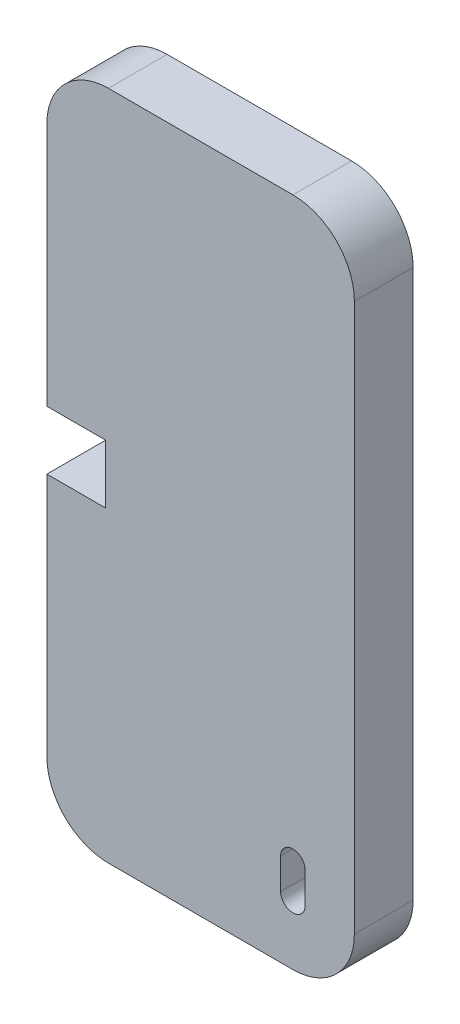
from build123d import *

# Parameters (mm, degrees)
BOSS_EXTRUDE1_DEPTH = 4.7752
SKETCH4_W           = 4.7752
SKETCH4_H           = 4.7752
CUT_EXTRUDE1_DEPTH  = 5.7752
CUT_EXTRUDE2_DEPTH  = 10


with BuildPart() as part:
    # Sketch1 → Boss-Extrude1 (new body)
    with BuildSketch(Plane.XY):
        with BuildLine():
            Line((-4.5504, 44.7752), (-4.5504, 0.2248))
            ThreePointArc((-4.5504, 0.2248), (-3.085933906, -3.310733906), (0.4496, -4.7752))
            Line((0.4496, -4.7752), (15.4496, -4.7752))
            ThreePointArc((15.4496, -4.7752), (18.985133906, -3.310733906), (20.4496, 0.2248))
            Line((20.4496, 0.2248), (20.4496, 44.7752))
            ThreePointArc((20.4496, 44.7752), (18.985133906, 48.310733906), (15.4496, 49.7752))
            Line((15.4496, 49.7752), (0.4496, 49.7752))
            ThreePointArc((0.4496, 49.7752), (-3.085933906, 48.310733906), (-4.5504, 44.7752))
        make_face()
    extrude(amount=BOSS_EXTRUDE1_DEPTH)

    # Sketch4 → Cut-Extrude1 (cut, through all)
    with BuildSketch(Plane.XY.offset(4.7752)):
        with Locations((-2.1628, 22.5)):
            Rectangle(SKETCH4_W, SKETCH4_H)
    extrude(amount=-CUT_EXTRUDE1_DEPTH, mode=Mode.SUBTRACT)

    # Sketch5 → Cut-Extrude2 (cut)
    with BuildSketch(Plane.XY.offset(4.7752)):
        with BuildLine():
            Line((16.4496, 0.2248), (16.4496, 2.7248))
            ThreePointArc((16.4496, 2.7248), (15.4496, 3.7248), (14.4496, 2.7248))
            Line((14.4496, 2.7248), (14.4496, 0.2248))
            ThreePointArc((14.4496, 0.2248), (15.4496, -0.7752), (16.4496, 0.2248))
        make_face()
    extrude(amount=-CUT_EXTRUDE2_DEPTH, mode=Mode.SUBTRACT)


solid = part.part
